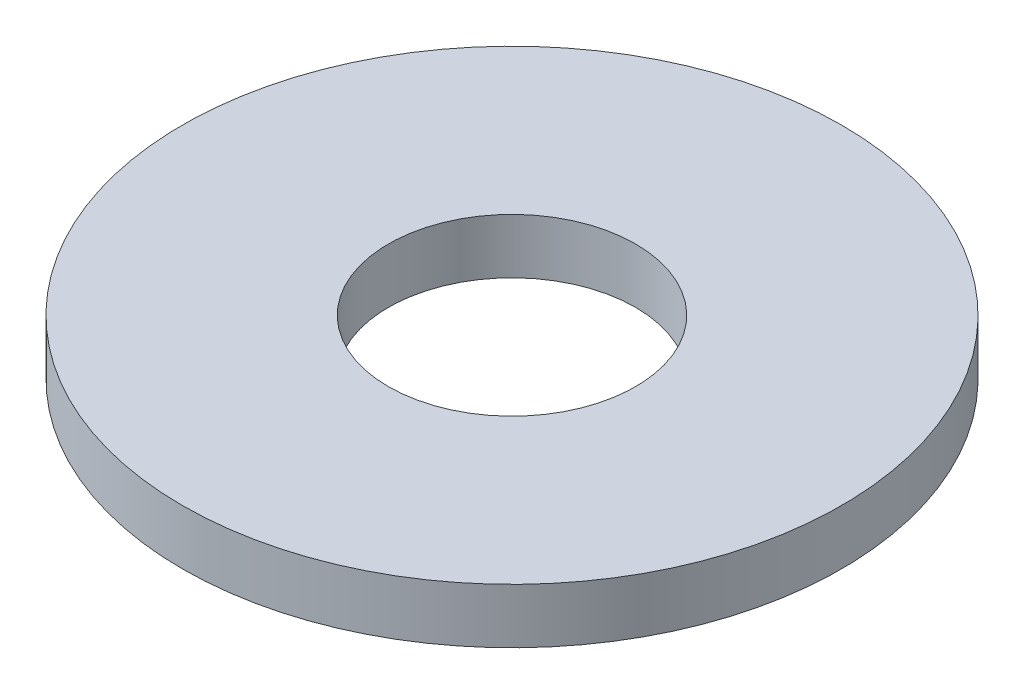
from build123d import *

# Parameters (mm, degrees)
SKETCH_1_R      = 6
SKETCH_1_R_2    = 2.25
EXTRUDE_1_DEPTH = 1


with BuildPart() as part:
    # Эскиз1 → Бобышка-Вытянуть1 (new body)
    with BuildSketch(Plane(origin=(0, 0, 0), x_dir=(1, 0, 0), z_dir=(0, 1, 0))):
        Circle(SKETCH_1_R)
        Circle(SKETCH_1_R_2, mode=Mode.SUBTRACT)
    extrude(amount=EXTRUDE_1_DEPTH)


solid = part.part
